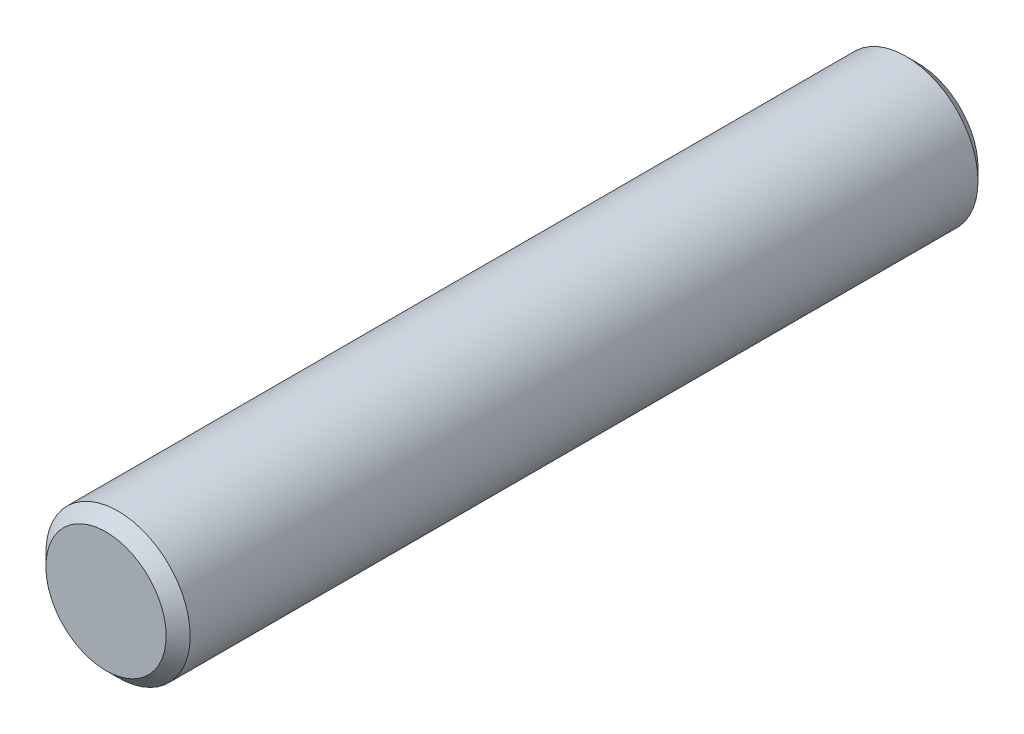
from build123d import *

# Parameters (mm, degrees)
SKETCH1_R           = 3
BOSS_EXTRUDE1_DEPTH = 33.75924676
CHAMFER1_SIZE       = 0.5


with BuildPart() as part:
    # Sketch1 → Boss-Extrude1 (new body)
    with BuildSketch(Plane.XY):
        Circle(SKETCH1_R)
    extrude(amount=BOSS_EXTRUDE1_DEPTH)

    # Chamfer1
    chamfer1_edges = [part.edges().sort_by_distance(p)[0] for p in [
        (-3, 0, 0),
        (-3, 0, 33.75924676),
    ]]
    chamfer(chamfer1_edges, length=CHAMFER1_SIZE)


solid = part.part
